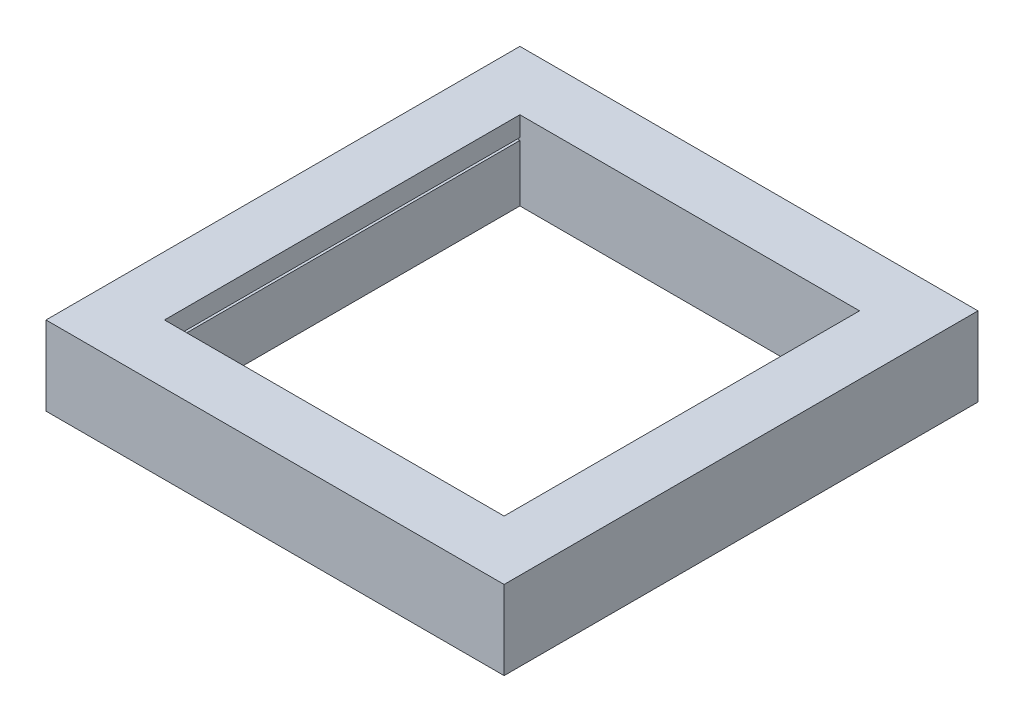
from build123d import *

# Parameters (mm, degrees)
SKETCH2_W           = 38.1
SKETCH2_H           = 304.8
SKETCH2_W_2         = 218.44
SKETCH2_H_2         = 38.1
BOSS_EXTRUDE1_DEPTH = 50.8
SKETCH4_W           = 228.6
SKETCH4_H           = 1.6002
CUT_EXTRUDE1_DEPTH  = 5.08


with BuildPart() as part:
    # Sketch2 → Boss-Extrude1 (new body)
    with BuildSketch(Plane(origin=(0, 0, 0), x_dir=(1, 0, 0), z_dir=(0, 1, 0))):
        with Locations((-128.27, 0)):
            Rectangle(SKETCH2_W, SKETCH2_H)
        with Locations((128.27, 0)):
            Rectangle(SKETCH2_W, SKETCH2_H)
        with Locations((0, -133.35)):
            Rectangle(SKETCH2_W_2, SKETCH2_H_2)
        with Locations((0, 133.35)):
            Rectangle(SKETCH2_W_2, SKETCH2_H_2)
    extrude(amount=BOSS_EXTRUDE1_DEPTH)

    # Sketch4 → Cut-Extrude1 (cut)
    with BuildSketch(Plane(origin=(-109.22, 0, 0), x_dir=(0, 0, -1), z_dir=(1, 0, 0))):
        with Locations((0, 37.2999)):
            Rectangle(SKETCH4_W, SKETCH4_H)
    cut_extrude1 = extrude(amount=-CUT_EXTRUDE1_DEPTH, mode=Mode.SUBTRACT)

    # Mirror1: Cut-Extrude1 across plane
    add(cut_extrude1.mirror(Plane(origin=(0, 0, 0), x_dir=(0, 0, 1), z_dir=(1, 0, 0))), mode=Mode.SUBTRACT)


solid = part.part
